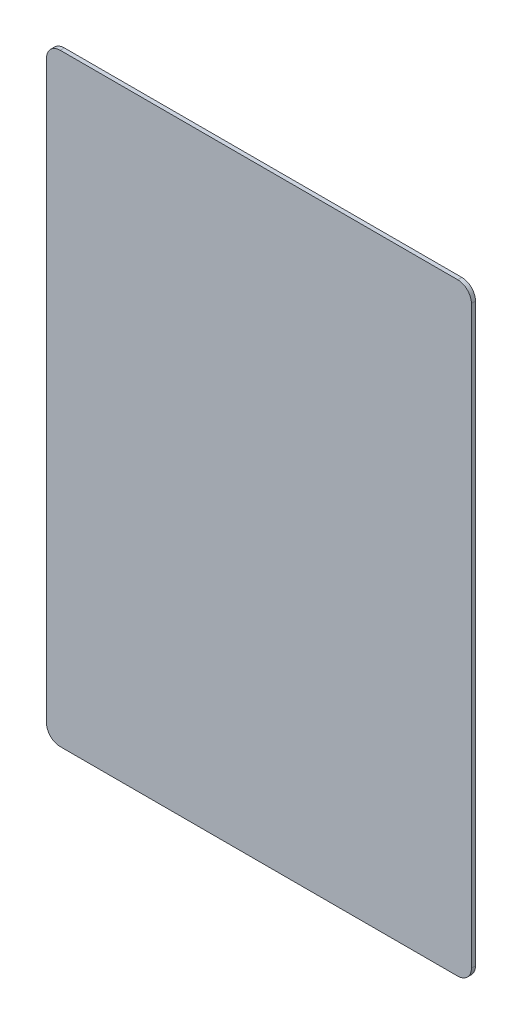
from build123d import *

# Parameters (mm, degrees)
SKETCH1_W           = 310
SKETCH1_H           = 440
BOSS_EXTRUDE1_DEPTH = 3
FILLET1_R           = 10


with BuildPart() as part:
    # Sketch1 → Boss-Extrude1 (new body)
    with BuildSketch(Plane.XY):
        with Locations((155, 220)):
            Rectangle(SKETCH1_W, SKETCH1_H)
    extrude(amount=BOSS_EXTRUDE1_DEPTH)

    # Fillet1
    fillet1_edges = [part.edges().sort_by_distance(p)[0] for p in [
        (0, 440, 1.5),
        (0, 0, 1.5),
        (310, 0, 1.5),
        (310, 440, 1.5),
    ]]
    fillet(fillet1_edges, radius=FILLET1_R)


solid = part.part
